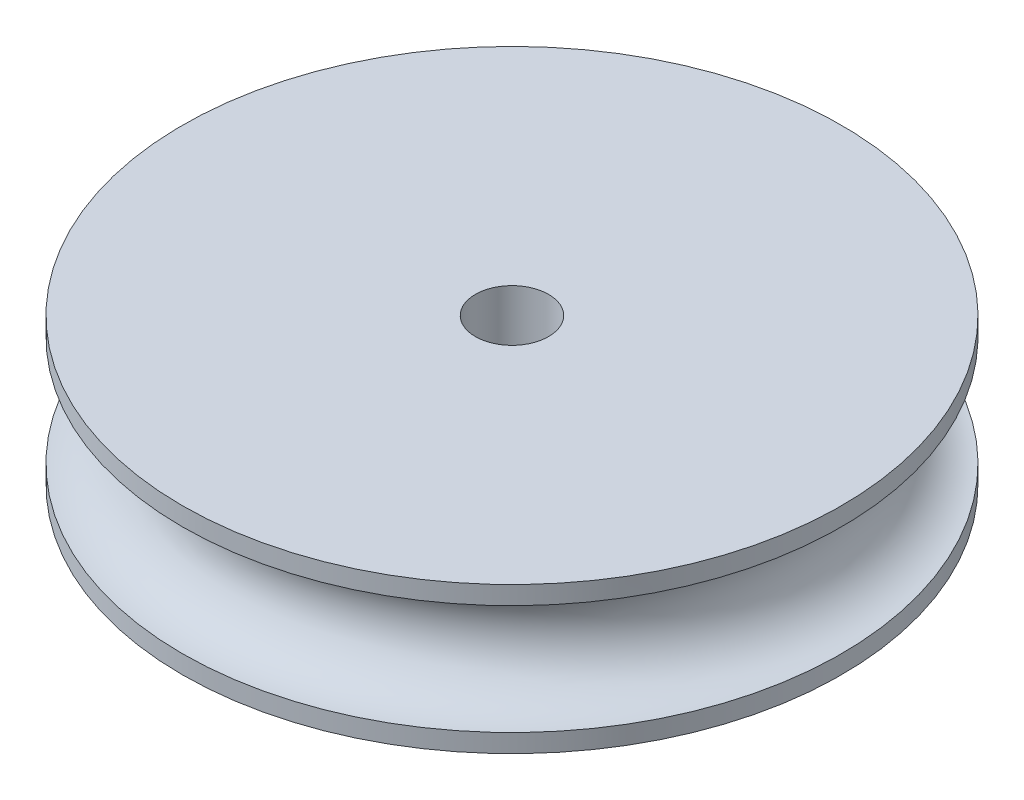
from build123d import *

# Parameters (mm, degrees)
SKETCH1_R           = 9
SKETCH1_R_2         = 1
BOSS_EXTRUDE1_DEPTH = 4
SKETCH2_R           = 1.5


with BuildPart() as part:
    # Sketch1 → Boss-Extrude1 (new body)
    with BuildSketch(Plane(origin=(0, 50.573034342, 0), x_dir=(1, 0, 0), z_dir=(0, 1, 0))):
        with Locations((0, -53)):
            Circle(SKETCH1_R)
        with Locations((0, -53)):
            Circle(SKETCH1_R_2, mode=Mode.SUBTRACT)
    extrude(amount=-BOSS_EXTRUDE1_DEPTH)

    # Sketch2 → Cut-Revolve1 (revolve, cut)
    with BuildSketch(Plane(origin=(0, 0, 0), x_dir=(0, 0, -1), z_dir=(1, 0, 0))):
        with Locations((-44, 48.573034342)):
            Circle(SKETCH2_R)
    revolve(axis=Axis((0, 46.573034342, 53), (0, 1, 0)), mode=Mode.SUBTRACT)


solid = part.part
